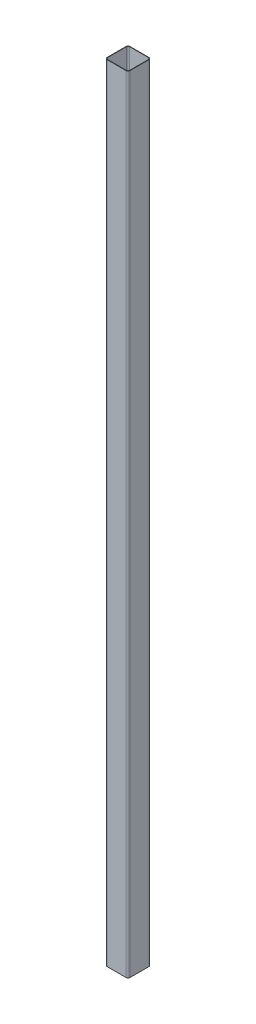
from build123d import *

# Parameters (mm, degrees)
BOSS_EXTRUDE1_DEPTH = 1219.2


with BuildPart() as part:
    # Sketch1 → Boss-Extrude1 (new body)
    with BuildSketch(Plane(origin=(0, 0, 0), x_dir=(1, 0, 0), z_dir=(0, 1, 0))):
        with BuildLine():
            Line((14.605, -17.78), (-14.605, -17.78))
            ThreePointArc((-14.605, -17.78), (-16.85006403, -16.85006403), (-17.78, -14.605))
            Line((-17.78, -14.605), (-17.78, 14.605))
            ThreePointArc((-17.78, 14.605), (-16.85006403, 16.85006403), (-14.605, 17.78))
            Line((-14.605, 17.78), (14.605, 17.78))
            ThreePointArc((14.605, 17.78), (16.85006403, 16.85006403), (17.78, 14.605))
            Line((17.78, 14.605), (17.78, -14.605))
            ThreePointArc((17.78, -14.605), (16.85006403, -16.85006403), (14.605, -17.78))
        make_face()
        with BuildLine():
            Line((14.605, 17.145), (-14.605, 17.145))
            ThreePointArc((-14.605, 17.145), (-16.401051224, 16.401051224), (-17.145, 14.605))
            Line((-17.145, 14.605), (-17.145, -14.605))
            ThreePointArc((-17.145, -14.605), (-16.401051224, -16.401051224), (-14.605, -17.145))
            Line((-14.605, -17.145), (14.605, -17.145))
            ThreePointArc((14.605, -17.145), (16.401051224, -16.401051224), (17.145, -14.605))
            Line((17.145, -14.605), (17.145, 14.605))
            ThreePointArc((17.145, 14.605), (16.401051224, 16.401051224), (14.605, 17.145))
        make_face(mode=Mode.SUBTRACT)
    extrude(amount=BOSS_EXTRUDE1_DEPTH)


solid = part.part
